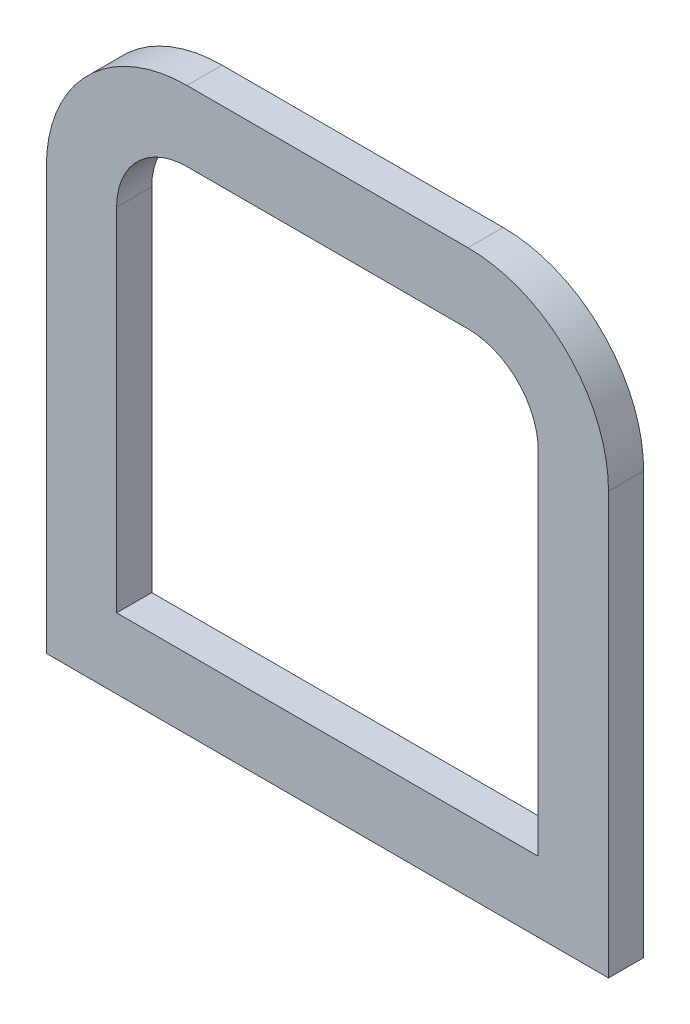
from build123d import *

# Parameters (mm, degrees)
BOSS_EXTRUDE2_DEPTH = 1


with BuildPart() as part:
    # Sketch1 → Boss-Extrude2 (new body)
    with BuildSketch(Plane.XY):
        with BuildLine():
            Line((-4, 8), (4, 8))
            ThreePointArc((4, 8), (6.828427125, 6.828427125), (8, 4))
            Line((8, 4), (8, -8))
            Line((8, -8), (-8, -8))
            Line((-8, -8), (-8, 4))
            ThreePointArc((-8, 4), (-6.828427125, 6.828427125), (-4, 8))
        make_face()
        with BuildLine():
            Line((-4, 6), (4, 6))
            ThreePointArc((4, 6), (5.414213562, 5.414213562), (6, 4))
            Line((6, 4), (6, -6))
            Line((6, -6), (-6, -6))
            Line((-6, -6), (-6, 4))
            ThreePointArc((-6, 4), (-5.414213562, 5.414213562), (-4, 6))
        make_face(mode=Mode.SUBTRACT)
    extrude(amount=BOSS_EXTRUDE2_DEPTH)


solid = part.part
